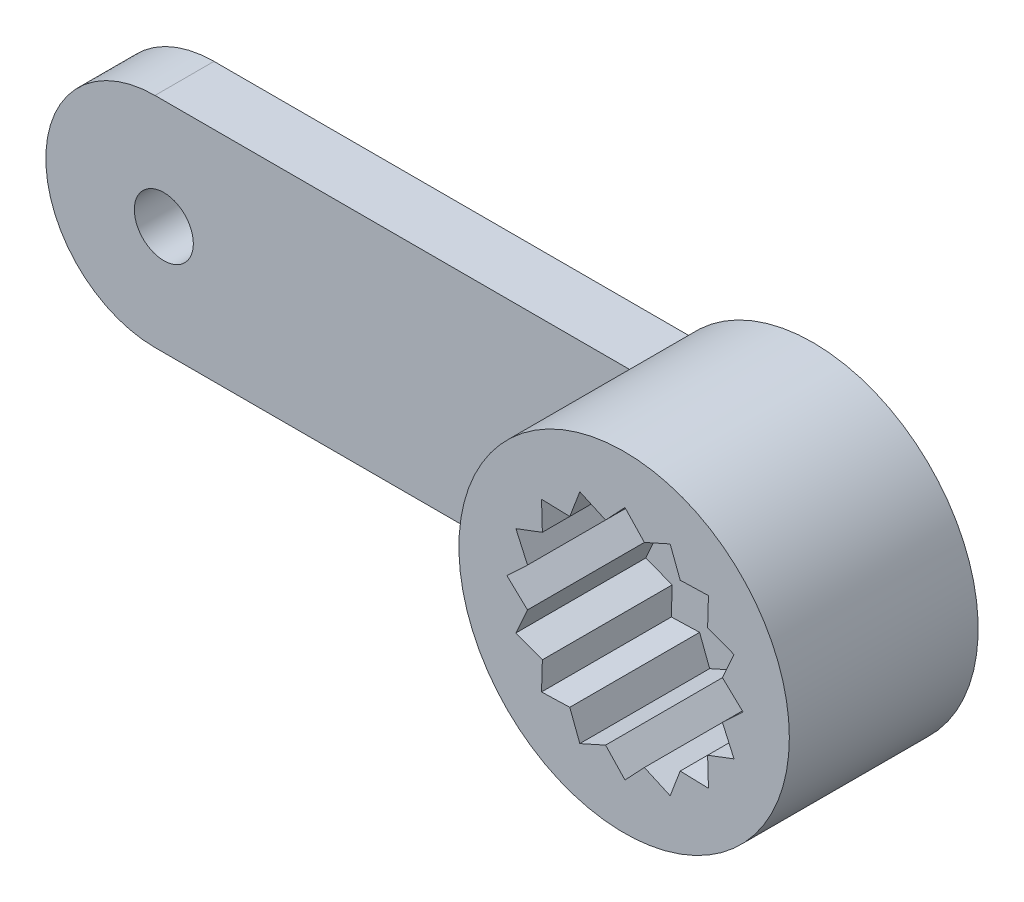
from build123d import *

# Parameters (mm, degrees)
SKETCH1_R           = 2.8
BOSS_EXTRUDE1_DEPTH = 3.2
CUT_EXTRUDE1_DEPTH  = 2.2
SKETCH3_R           = 0.75
CUT_EXTRUDE2_DEPTH  = 1
BOSS_EXTRUDE2_DEPTH = 1
CUT_EXTRUDE3_REACH  = 14.731
SKETCH5_R           = 0.5


with BuildPart() as part:
    # Sketch1 → Boss-Extrude1 (new body)
    with BuildSketch(Plane.XY):
        Circle(SKETCH1_R)
    extrude(amount=BOSS_EXTRUDE1_DEPTH)

    # Sketch2 → Cut-Extrude1 (cut)
    with BuildSketch(Plane.XY.offset(3.2)):
        Polygon((0.014651949, 1.985348051), (-0.313876209, 1.636970634), (-0.750714916, 1.833107116), (-0.920917091, 1.385526068), (-1.399561614, 1.399561614), (-1.385526068, 0.920917091), (-1.833107116, 0.750714916), (-1.636970634, 0.313876209), (-1.985348051, -0.014651949), (-1.636970634, -0.343180107), (-1.833107116, -0.780018813), (-1.385526068, -0.950220989), (-1.399561614, -1.428865511), (-0.920917091, -1.414829965), (-0.750714916, -1.862411014), (-0.313876209, -1.666274532), (0.014651949, -2.014651949), (0.343180107, -1.666274532), (0.780018813, -1.862411014), (0.950220989, -1.414829965), (1.428865511, -1.428865511), (1.414829965, -0.950220989), (1.862411014, -0.780018813), (1.666274532, -0.343180107), (2.014651949, -0.014651949), (1.666274532, 0.313876209), (1.862411014, 0.750714916), (1.414829965, 0.920917091), (1.428865511, 1.399561614), (0.950220989, 1.385526068), (0.780018813, 1.833107116), (0.343180107, 1.636970634), align=None)
    extrude(amount=-CUT_EXTRUDE1_DEPTH, mode=Mode.SUBTRACT)

    # Sketch3 → Cut-Extrude2 (cut)
    with BuildSketch(Plane.XY):
        Circle(SKETCH3_R)
    extrude(amount=CUT_EXTRUDE2_DEPTH, mode=Mode.SUBTRACT)

    # Sketch4 → Boss-Extrude2 (add)
    with BuildSketch(Plane.XY):
        with BuildLine():
            Line((-0.75, -1.85), (-0.75, 1.85))
            Line((-0.75, 1.85), (-10.15, 1.85))
            ThreePointArc((-10.15, 1.85), (-12, 0), (-10.15, -1.85))
            Line((-10.15, -1.85), (-0.75, -1.85))
        make_face()
    extrude(amount=BOSS_EXTRUDE2_DEPTH)

    # Sketch5 → Cut-Extrude3 (cut, up to next)
    with BuildSketch(Plane(origin=(0, 0, 0), x_dir=(-1, 0, 0), z_dir=(0, 0, -1)), mode=Mode.PRIVATE) as cut_extrude3_sk1:
        with Locations((10, 0)):
            Circle(SKETCH5_R)
    cut_extrude3_tool1 = extrude(cut_extrude3_sk1.sketch, amount=-CUT_EXTRUDE3_REACH, mode=Mode.PRIVATE) & part.part
    add(cut_extrude3_tool1.solids().sort_by_distance((-10, 0, 0))[0], mode=Mode.SUBTRACT)


solid = part.part
